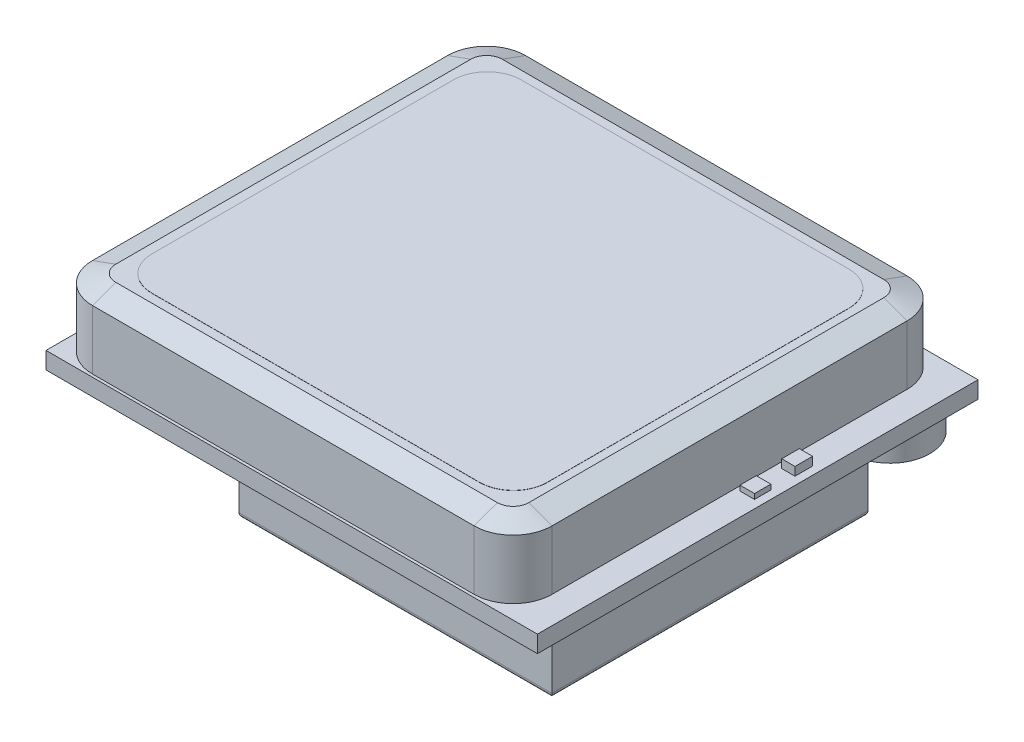
from build123d import *
from OCP.BRepFilletAPI import BRepFilletAPI_MakeChamfer

# Parameters (mm, degrees)
SKETCH_2_W          = 29
SKETCH_2_H          = 26
EXTRUDE_1_DEPTH     = 1
EXTRUDE_2_DEPTH     = 4
EXTRUDE_3_DEPTH     = 0.01
SKETCH_5_W          = 0.784221302
SKETCH_5_H          = 1.036614364
EXTRUDE_4_DEPTH     = 0.5
SKETCH_6_W          = 0.860751419
SKETCH_6_H          = 0.964798294
EXTRUDE_5_DEPTH     = 0.3
SKETCH_7_W          = 18.46780689
SKETCH_7_H          = 18.660682157
EXTRUDE_6_DEPTH     = 3
FILLET_1_R          = 0.3
SKETCH_8_R          = 2.347351185
EXTRUDE_7_DEPTH     = 1.5
SKETCH_9_W          = 2.884936077
SKETCH_9_H          = 1.300585937
SKETCH_9_W_2        = 3.097610801
SKETCH_9_H_2        = 3.124546547
SKETCH_9_W_3        = 1.606960568
SKETCH_9_H_3        = 1.059133102
SKETCH_9_W_4        = 2.790267896
SKETCH_9_H_4        = 1.285568455
EXTRUDE_8_DEPTH     = 0.5
SKETCH_10_W         = 1.557077247
SKETCH_10_H         = 2.060837534
EXTRUDE_9_DEPTH     = 0.8
SKETCH_11_W         = 0.626788403
SKETCH_11_H         = 0.569807639
SKETCH_11_W_2       = 0.607794815
SKETCH_11_H_2       = 0.664775579
SKETCH_11_W_3       = 0.531820463
SKETCH_11_W_4       = 0.531820464
SKETCH_11_H_3       = 0.598298021
SKETCH_11_H_4       = 0.626788403
SKETCH_11_H_5       = 0.567155565
SKETCH_11_H_6       = 0.62846968
SKETCH_11_H_7       = 0.613141151
SKETCH_11_W_5       = 0.43686307
SKETCH_11_H_8       = 0.536498507
SKETCH_11_W_6       = 0.673382791
SKETCH_11_H_9       = 0.629938741
SKETCH_11_W_7       = 0.619077727
SKETCH_11_H_10      = 0.673382791
SKETCH_11_W_8       = 0.641296586
SKETCH_11_W_9       = 0.468736414
SKETCH_11_H_11      = 0.554357743
EXTRUDE_10_DEPTH    = 0.4
EXTRUDE_11_DEPTH    = 3
EXTRUDE_12_DEPTH    = 1
SKETCH_14_R         = 0.127535106
CUT_EXTRUDE_1_DEPTH = 4
CHAMFER_1_SIZE      = 0.5
CHAMFER_1_SIZE2     = 1.37373871


with BuildPart() as part:
    # 草图2 → 凸台-拉伸1 (new body)
    with BuildSketch(Plane(origin=(0, 0, 0), x_dir=(1, 0, 0), z_dir=(0, 1, 0))):
        with Locations((14.5, 13)):
            Rectangle(SKETCH_2_W, SKETCH_2_H)
    extrude(amount=EXTRUDE_1_DEPTH)

    # 草图3 → 凸台-拉伸2 (add)
    with BuildSketch(Plane(origin=(0, 1, 0), x_dir=(1, 0, 0), z_dir=(0, 1, 0))):
        with BuildLine():
            Line((25.098533533, 25.717712969), (2.579235135, 25.717712969))
            ThreePointArc((2.579235135, 25.717712969), (0.952889539, 25.044058566), (0.279235135, 23.417712969))
            Line((0.279235135, 23.417712969), (0.279235135, 2.464690598))
            ThreePointArc((0.279235135, 2.464690598), (0.952889539, 0.838345002), (2.579235135, 0.164690598))
            Line((2.579235135, 0.164690598), (25.098533533, 0.164690598))
            ThreePointArc((25.098533533, 0.164690598), (26.724879129, 0.838345002), (27.398533533, 2.464690598))
            Line((27.398533533, 2.464690598), (27.398533533, 23.417712969))
            ThreePointArc((27.398533533, 23.417712969), (26.724879129, 25.044058566), (25.098533533, 25.717712969))
        make_face()
    extrude(amount=EXTRUDE_2_DEPTH)

    # 草图4 → 凸台-拉伸3 (add)
    with BuildSketch(Plane(origin=(0, 5, 0), x_dir=(1, 0, 0), z_dir=(0, 1, 0))):
        with BuildLine():
            Line((4.204201679, 23.837179108), (23.54210908, 23.837179108))
            ThreePointArc((23.54210908, 23.837179108), (24.956322643, 23.251392671), (25.54210908, 21.837179108))
            Line((25.54210908, 21.837179108), (25.54210908, 4.042273849))
            ThreePointArc((25.54210908, 4.042273849), (24.956322643, 2.628060287), (23.54210908, 2.042273849))
            Line((23.54210908, 2.042273849), (4.204201679, 2.042273849))
            ThreePointArc((4.204201679, 2.042273849), (2.789988117, 2.628060287), (2.204201679, 4.042273849))
            Line((2.204201679, 4.042273849), (2.204201679, 21.837179108))
            ThreePointArc((2.204201679, 21.837179108), (2.789988117, 23.251392671), (4.204201679, 23.837179108))
        make_face()
    extrude(amount=EXTRUDE_3_DEPTH)

    # 草图5 → 凸台-拉伸4 (add)
    with BuildSketch(Plane(origin=(0, 1, 0), x_dir=(1, 0, 0), z_dir=(0, 1, 0))):
        with Locations((28.137496493, 16.188758382)):
            Rectangle(SKETCH_5_W, SKETCH_5_H)
    extrude(amount=EXTRUDE_4_DEPTH)

    # 草图6 → 凸台-拉伸5 (add)
    with BuildSketch(Plane(origin=(0, 1, 0), x_dir=(1, 0, 0), z_dir=(0, 1, 0))):
        with Locations((28.091100872, 13.772193793)):
            Rectangle(SKETCH_6_W, SKETCH_6_H)
    extrude(amount=EXTRUDE_5_DEPTH)

    # 草图7 → 凸台-拉伸6 (add)
    with BuildSketch(Plane.XZ):
        with Locations((19.514756962, -10.432347998)):
            Rectangle(SKETCH_7_W, SKETCH_7_H)
    extrude(amount=EXTRUDE_6_DEPTH)

    # 圆角1
    fillet_1_edges = [part.edges().sort_by_distance(p)[0] for p in [
        (10.280853517, -3, -10.432347998),
        (19.514756962, -3, -19.762689076),
        (28.748660407, -3, -10.432347998),
        (19.514756962, -3, -1.102006919),
    ]]
    fillet(fillet_1_edges, radius=FILLET_1_R)

    # 草图8 → 凸台-拉伸7 (add)
    with BuildSketch(Plane.XZ):
        with Locations(Location((26.513723802, -23.294441839, 0), (0, 0, 270))):
            Circle(SKETCH_8_R)
    extrude(amount=EXTRUDE_7_DEPTH)

    # 草图9 → 凸台-拉伸8 (add)
    with BuildSketch(Plane.XZ):
        with Locations((2.773973139, -2.797956416)):
            Rectangle(SKETCH_9_W, SKETCH_9_H)
        with Locations((5.287865795, -23.096109688)):
            Rectangle(SKETCH_9_W_2, SKETCH_9_H_2)
        with Locations((15.517395011, -24.903778891)):
            Rectangle(SKETCH_9_W_3, SKETCH_9_H_3)
        with Locations((18.840881641, -23.884819804)):
            Rectangle(SKETCH_9_W_4, SKETCH_9_H_4)
    extrude(amount=EXTRUDE_8_DEPTH)

    # 草图10 → 凸台-拉伸9 (add)
    with BuildSketch(Plane.XZ):
        with Locations((1.610089636, -21.286422446)):
            Rectangle(SKETCH_10_W, SKETCH_10_H)
    extrude(amount=EXTRUDE_9_DEPTH)

    # 草图11 → 凸台-拉伸10 (add)
    with BuildSketch(Plane.XZ):
        with Locations((5.531871042, -2.03095706)):
            Rectangle(SKETCH_11_W, SKETCH_11_H)
        with Locations((6.035201123, -4.186729294)):
            Rectangle(SKETCH_11_W_2, SKETCH_11_H_2)
        with Locations((7.260287547, -4.186729294)):
            Rectangle(SKETCH_11_W_3, SKETCH_11_H_2)
        with Locations((8.399902825, -4.153490515)):
            Rectangle(SKETCH_11_W_4, SKETCH_11_H_3)
        with Locations((7.260287547, -6.627405348)):
            Rectangle(SKETCH_11_W_3, SKETCH_11_H_4)
        with Locations((8.399902825, -6.627405348)):
            Rectangle(SKETCH_11_W_4, SKETCH_11_H_4)
        with Locations((8.399902825, -13.107613117)):
            Rectangle(SKETCH_11_W_4, SKETCH_11_H_5)
        with Locations((8.399902825, -15.22295009)):
            Rectangle(SKETCH_11_W_4, SKETCH_11_H_6)
        with Locations((8.399902825, -17.422593971)):
            Rectangle(SKETCH_11_W_4, SKETCH_11_H_7)
        with Locations((6.704371838, -17.330622799)):
            Rectangle(SKETCH_11_W_5, SKETCH_11_H_8)
        with Locations((12.568925258, -24.947915884)):
            Rectangle(SKETCH_11_W_6, SKETCH_11_H_9)
        with Locations((21.610718383, -22.92776751)):
            Rectangle(SKETCH_11_W_7, SKETCH_11_H_10)
        with Locations((1.806784012, -24.947915884)):
            Rectangle(SKETCH_11_W_8, SKETCH_11_H_9)
        with Locations((8.165534618, -22.650588638)):
            Rectangle(SKETCH_11_W_9, SKETCH_11_H_11)
    extrude(amount=EXTRUDE_10_DEPTH)

    # 草图12 → 凸台-拉伸11 (add)
    with BuildSketch(Plane.XZ):
        Polygon((1.032908787, -7.244654806), (2.701305554, -7.244654806), (2.701305554, -5.740362639), (4.862016122, -5.740362639), (5.450057605, -6.287377972), (5.450057605, -7.244654806), (5.819292955, -7.244654806), (5.819292955, -8.69424544), (5.450057605, -8.69424544), (5.450057605, -9.10450694), (5.819292955, -9.10450694), (5.819292955, -10.034433007), (5.450057605, -10.034433007), (5.450057605, -10.403668357), (5.819292955, -10.403668357), (5.819292955, -11.388295957), (5.450057605, -11.388295957), (5.450057605, -11.757531308), (5.819292955, -11.757531308), (5.819292955, -12.714808141), (5.450057605, -12.714808141), (5.450057605, -13.029341958), (5.819292955, -13.029341958), (5.819292955, -14.082346475), (5.545785289, -14.082346475), (5.545785289, -14.328503375), (5.819292955, -14.328503375), (5.819292955, -15.395183276), (5.545785289, -15.395183276), (5.545785289, -15.737067859), (5.819292955, -15.737067859), (5.819292955, -17.33708771), (5.450057605, -17.33708771), (5.450057605, -18.143935327), (4.77631996, -18.868203295), (2.701305554, -18.868203295), (2.701305554, -17.41914001), (1.032908787, -17.41914001), align=None)
    extrude(amount=EXTRUDE_11_DEPTH)

    # 草图13 → 凸台-拉伸12 (add)
    with BuildSketch(Plane.XZ.offset(3)):
        Polygon((1.690203867, -17.41914001), (5.450057605, -17.41914001), (5.450057605, -17.33708771), (5.819292955, -17.33708771), (5.819292955, -15.737067859), (5.545785289, -15.737067859), (5.545785289, -15.395183276), (5.819292955, -15.395183276), (5.819292955, -14.328503375), (5.545785289, -14.328503375), (5.545785289, -14.082346475), (5.819292955, -14.082346475), (5.819292955, -13.029341958), (5.450057605, -13.029341958), (5.450057605, -12.714808141), (5.819292955, -12.714808141), (5.819292955, -11.757531308), (5.450057605, -11.757531308), (5.450057605, -11.388295957), (5.819292955, -11.388295957), (5.819292955, -10.403668357), (5.450057605, -10.403668357), (5.450057605, -10.034433007), (5.819292955, -10.034433007), (5.819292955, -9.10450694), (5.450057605, -9.10450694), (5.450057605, -8.69424544), (5.819292955, -8.69424544), (5.819292955, -7.244654806), (1.690203867, -7.244654806), (1.690203867, -7.744654806), (2.701305554, -7.744654806), (2.701305554, -16.91914001), (1.690203867, -16.91914001), align=None)
    extrude(amount=EXTRUDE_12_DEPTH)

    # 草图14 → 切除-拉伸1 (cut)
    with BuildSketch(Plane.ZY.offset(-1.032908787)):
        Polygon((-17.222040031, -0.182983906), (-17.222040031, -2.817480892), (-16.921164331, -2.817480892), (-16.91914001, -3), (-7.744654806, -3), (-7.744654806, -2.817480892), (-7.410556827, -2.817480892), (-7.410556827, -0.182983906), align=None)
        with Locations((-11.727067082, -2.127692515)):
            Circle(SKETCH_14_R, mode=Mode.SUBTRACT)
        with Locations((-10.457067082, -2.127692515)):
            Circle(SKETCH_14_R, mode=Mode.SUBTRACT)
        with Locations((-9.187067082, -2.127692515)):
            Circle(SKETCH_14_R, mode=Mode.SUBTRACT)
        with Locations((-12.997067082, -2.127692515)):
            Circle(SKETCH_14_R, mode=Mode.SUBTRACT)
        with Locations((-14.267067082, -2.127692515)):
            Circle(SKETCH_14_R, mode=Mode.SUBTRACT)
        with Locations((-15.537067082, -2.127692515)):
            Circle(SKETCH_14_R, mode=Mode.SUBTRACT)
    extrude(amount=-CUT_EXTRUDE_1_DEPTH, mode=Mode.SUBTRACT)

    # 倒角1: one chamfer whose edges measure the first distance from different faces: ONE call of the kernel's chamfer builder (chamfer() names one face for all edges)
    chamfer_1_edges_1 = [part.edges().sort_by_distance(p)[0] for p in [
        (26.724879129, 5, -0.838345002),
    ]]
    chamfer_1_side_1 = [part.faces().sort_by_distance(p)[0] for p in [
        (26.724879129, 3, -0.838345002),
    ]]
    chamfer_1_edges_2 = [part.edges().sort_by_distance(p)[0] for p in [
        (27.398533533, 5, -12.941201784),
    ]]
    chamfer_1_side_2 = [part.faces().sort_by_distance(p)[0] for p in [
        (27.398533533, 3, -12.941201784),
    ]]
    chamfer_1_edges_3 = [part.edges().sort_by_distance(p)[0] for p in [
        (26.724879129, 5, -25.044058566),
    ]]
    chamfer_1_side_3 = [part.faces().sort_by_distance(p)[0] for p in [
        (26.724879129, 3, -25.044058566),
    ]]
    chamfer_1_edges_4 = [part.edges().sort_by_distance(p)[0] for p in [
        (13.838884334, 5, -25.717712969),
    ]]
    chamfer_1_side_4 = [part.faces().sort_by_distance(p)[0] for p in [
        (13.838884334, 3, -25.717712969),
    ]]
    chamfer_1_edges_5 = [part.edges().sort_by_distance(p)[0] for p in [
        (0.952889539, 5, -25.044058566),
    ]]
    chamfer_1_side_5 = [part.faces().sort_by_distance(p)[0] for p in [
        (0.952889539, 3, -25.044058566),
    ]]
    chamfer_1_edges_6 = [part.edges().sort_by_distance(p)[0] for p in [
        (0.279235135, 5, -12.941201784),
    ]]
    chamfer_1_side_6 = [part.faces().sort_by_distance(p)[0] for p in [
        (0.279235135, 3, -12.941201784),
    ]]
    chamfer_1_edges_7 = [part.edges().sort_by_distance(p)[0] for p in [
        (0.952889539, 5, -0.838345002),
    ]]
    chamfer_1_side_7 = [part.faces().sort_by_distance(p)[0] for p in [
        (0.952889539, 3, -0.838345002),
    ]]
    chamfer_1_edges_8 = [part.edges().sort_by_distance(p)[0] for p in [
        (13.838884334, 5, -0.164690598),
    ]]
    chamfer_1_side_8 = [part.faces().sort_by_distance(p)[0] for p in [
        (13.838884334, 3, -0.164690598),
    ]]
    chamfer_1 = BRepFilletAPI_MakeChamfer(part.part.solid().wrapped)
    for e in chamfer_1_edges_1:
        chamfer_1.Add(CHAMFER_1_SIZE, CHAMFER_1_SIZE2, e.wrapped, chamfer_1_side_1[0].wrapped)  # the first distance lies on this face
    for e in chamfer_1_edges_2:
        chamfer_1.Add(CHAMFER_1_SIZE, CHAMFER_1_SIZE2, e.wrapped, chamfer_1_side_2[0].wrapped)  # the first distance lies on this face
    for e in chamfer_1_edges_3:
        chamfer_1.Add(CHAMFER_1_SIZE, CHAMFER_1_SIZE2, e.wrapped, chamfer_1_side_3[0].wrapped)  # the first distance lies on this face
    for e in chamfer_1_edges_4:
        chamfer_1.Add(CHAMFER_1_SIZE, CHAMFER_1_SIZE2, e.wrapped, chamfer_1_side_4[0].wrapped)  # the first distance lies on this face
    for e in chamfer_1_edges_5:
        chamfer_1.Add(CHAMFER_1_SIZE, CHAMFER_1_SIZE2, e.wrapped, chamfer_1_side_5[0].wrapped)  # the first distance lies on this face
    for e in chamfer_1_edges_6:
        chamfer_1.Add(CHAMFER_1_SIZE, CHAMFER_1_SIZE2, e.wrapped, chamfer_1_side_6[0].wrapped)  # the first distance lies on this face
    for e in chamfer_1_edges_7:
        chamfer_1.Add(CHAMFER_1_SIZE, CHAMFER_1_SIZE2, e.wrapped, chamfer_1_side_7[0].wrapped)  # the first distance lies on this face
    for e in chamfer_1_edges_8:
        chamfer_1.Add(CHAMFER_1_SIZE, CHAMFER_1_SIZE2, e.wrapped, chamfer_1_side_8[0].wrapped)  # the first distance lies on this face
    add(Compound.cast(chamfer_1.Shape()), mode=Mode.REPLACE)


solid = part.part
